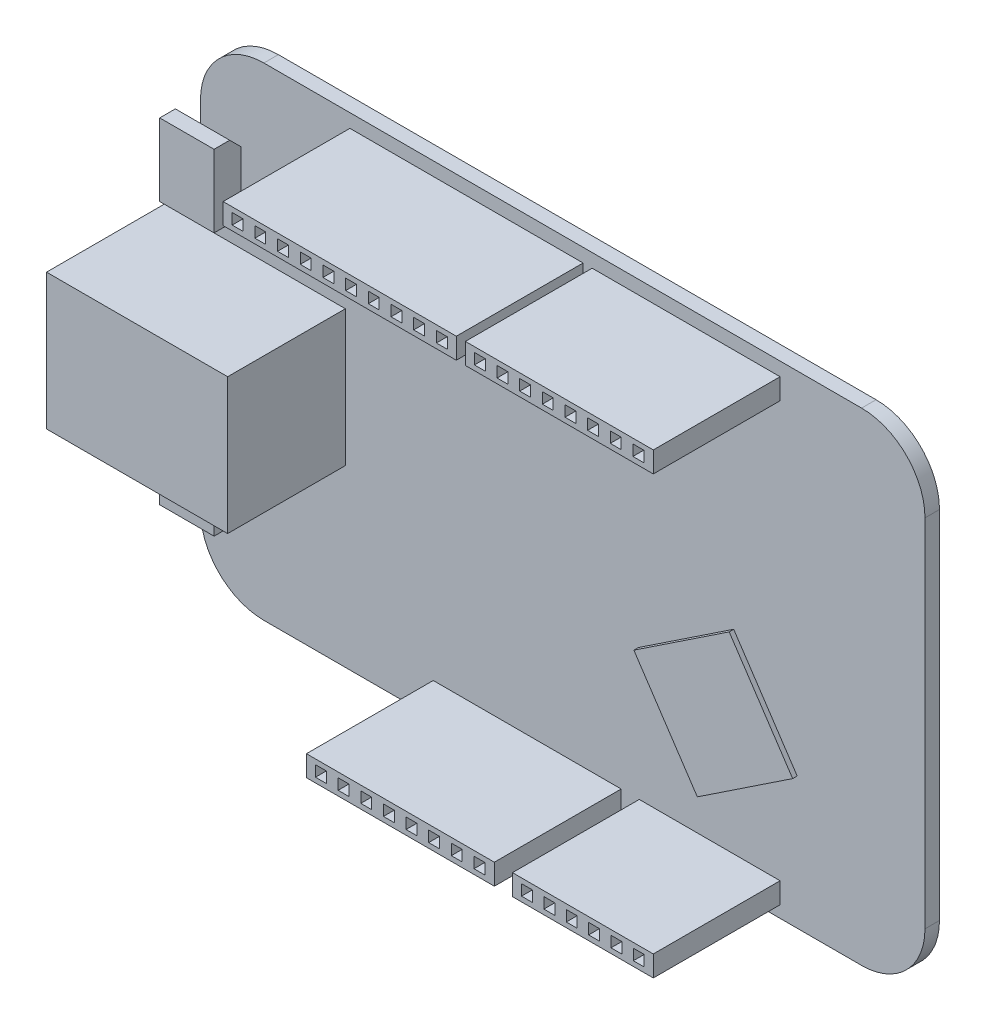
from build123d import *

# Parameters (mm, degrees)
ESQUISSE1_W         = 80
ESQUISSE1_H         = 53.3
BOSS_EXTRU_1_DEPTH  = 1.6
ESQUISSE4_W         = 15.55
ESQUISSE4_H         = 2.3
ESQUISSE4_W_2       = 1.2
ESQUISSE4_H_2       = 1.2
BOSS_EXTRU_4_DEPTH  = 14
ESQUISSE8_W         = 20.75
ESQUISSE8_H         = 2.3
ESQUISSE8_W_2       = 1.2
ESQUISSE8_H_2       = 1.2
BOSS_EXTRU_6_DEPTH  = 14
ESQUISSE19_W        = 20.75
ESQUISSE19_H        = 2.3
ESQUISSE19_W_2      = 1.2
ESQUISSE19_H_2      = 1.2
BOSS_EXTRU_15_DEPTH = 14
ESQUISSE20_W        = 25.75
ESQUISSE20_H        = 2.3
ESQUISSE20_W_2      = 1.2
ESQUISSE20_H_2      = 1.2
BOSS_EXTRU_16_DEPTH = 14
FILLET1_R           = 7
BOSS_EXTRUDE1_DEPTH = 0.5
SKETCH2_W           = 20
SKETCH2_H           = 15
BOSS_EXTRUDE2_DEPTH = 13
SKETCH3_W           = 6
SKETCH3_H           = 8
BOSS_EXTRUDE3_DEPTH = 3
CUT_EXTRUDE1_DEPTH  = 6
CUT_EXTRUDE2_DEPTH  = 18


with BuildPart() as part:
    # Esquisse1 → Boss.-Extru.1 (new body)
    with BuildSketch(Plane.XY):
        with Locations((40, 26.65)):
            Rectangle(ESQUISSE1_W, ESQUISSE1_H)
    extrude(amount=BOSS_EXTRU_1_DEPTH)

    # Fillet1
    fillet1_edges = [part.edges().sort_by_distance(p)[0] for p in [
        (0, 0, 0.8),
        (0, 53.3, 0.8),
        (80, 53.3, 0.8),
        (80, 0, 0.8),
    ]]
    fillet(fillet1_edges, radius=FILLET1_R)

    # Sketch1 → Boss-Extrude1 (add)
    with BuildSketch(Plane.XY.offset(1.6)):
        Polygon((55.362625471, 7.551462799), (65.888368636, 14.561039023), (58.878792412, 25.086782188), (48.353049247, 18.077205964), align=None)
    extrude(amount=BOSS_EXTRUDE1_DEPTH)

    # Sketch2 → Boss-Extrude2 (add)
    with BuildSketch(Plane.XY.offset(1.6)):
        with Locations((6, 26.8)):
            Rectangle(SKETCH2_W, SKETCH2_H)
    extrude(amount=BOSS_EXTRUDE2_DEPTH)

    # Sketch3 → Boss-Extrude3 (add)
    with BuildSketch(Plane.XY.offset(1.6)):
        with Locations((1.5, 41.3)):
            Rectangle(SKETCH3_W, SKETCH3_H)
        with Locations((1.5, 12.3)):
            Rectangle(SKETCH3_W, SKETCH3_H)
    extrude(amount=BOSS_EXTRUDE3_DEPTH)

    # Sketch4 → Cut-Extrude1 (cut)
    with BuildSketch(Plane.ZY.offset(1.5)):
        Polygon((2.872954099, 8.3), (1.6, 9.572630293), (1.6, 8.3), align=None)
        Polygon((2.872954099, 16.3), (1.6, 16.3), (1.6, 15.027369707), align=None)
        Polygon((2.873277986, 37.3), (1.6, 38.572954099), (1.6, 37.3), align=None)
        Polygon((2.872630293, 45.3), (1.6, 44.027045901), (1.6, 45.3), align=None)
    extrude(amount=-CUT_EXTRUDE1_DEPTH, mode=Mode.SUBTRACT)

    # Sketch5 → Cut-Extrude2 (cut)
    with BuildSketch(Plane.ZY.offset(4)):
        Polygon((13.6, 33.3), (3.6, 33.3), (3.6, 30.3), (2.6, 30.3), (2.6, 23.3), (3.6, 23.3), (3.6, 20.3), (13.6, 20.3), align=None)
    extrude(amount=-CUT_EXTRUDE2_DEPTH, mode=Mode.SUBTRACT)


with BuildPart() as body_2:
    # Esquisse4 → Boss.-Extru.4 (new body)
    with BuildSketch(Plane.XY.offset(1.6)):
        with Locations((56.225, 2.45)):
            Rectangle(ESQUISSE4_W, ESQUISSE4_H)
        with Locations((50.05, 2.45)):
            Rectangle(ESQUISSE4_W_2, ESQUISSE4_H_2, mode=Mode.SUBTRACT)
        with Locations((52.52, 2.45)):
            Rectangle(ESQUISSE4_W_2, ESQUISSE4_H_2, mode=Mode.SUBTRACT)
        with Locations((54.99, 2.45)):
            Rectangle(ESQUISSE4_W_2, ESQUISSE4_H_2, mode=Mode.SUBTRACT)
        with Locations((57.46, 2.45)):
            Rectangle(ESQUISSE4_W_2, ESQUISSE4_H_2, mode=Mode.SUBTRACT)
        with Locations((59.93, 2.45)):
            Rectangle(ESQUISSE4_W_2, ESQUISSE4_H_2, mode=Mode.SUBTRACT)
        with Locations((62.4, 2.45)):
            Rectangle(ESQUISSE4_W_2, ESQUISSE4_H_2, mode=Mode.SUBTRACT)
    extrude(amount=BOSS_EXTRU_4_DEPTH)


with BuildPart() as body_3:
    # Esquisse8 → Boss.-Extru.6 (new body)
    with BuildSketch(Plane.XY.offset(1.6)):
        with Locations((36.075, 2.45)):
            Rectangle(ESQUISSE8_W, ESQUISSE8_H)
        with Locations((27.3, 2.45)):
            Rectangle(ESQUISSE8_W_2, ESQUISSE8_H_2, mode=Mode.SUBTRACT)
        with Locations((29.8, 2.45)):
            Rectangle(ESQUISSE8_W_2, ESQUISSE8_H_2, mode=Mode.SUBTRACT)
        with Locations((32.3, 2.45)):
            Rectangle(ESQUISSE8_W_2, ESQUISSE8_H_2, mode=Mode.SUBTRACT)
        with Locations((34.8, 2.45)):
            Rectangle(ESQUISSE8_W_2, ESQUISSE8_H_2, mode=Mode.SUBTRACT)
        with Locations((37.3, 2.45)):
            Rectangle(ESQUISSE8_W_2, ESQUISSE8_H_2, mode=Mode.SUBTRACT)
        with Locations((39.8, 2.45)):
            Rectangle(ESQUISSE8_W_2, ESQUISSE8_H_2, mode=Mode.SUBTRACT)
        with Locations((42.3, 2.45)):
            Rectangle(ESQUISSE8_W_2, ESQUISSE8_H_2, mode=Mode.SUBTRACT)
        with Locations((44.8, 2.45)):
            Rectangle(ESQUISSE8_W_2, ESQUISSE8_H_2, mode=Mode.SUBTRACT)
    extrude(amount=BOSS_EXTRU_6_DEPTH)


with BuildPart() as body_4:
    # Esquisse19 → Boss.-Extru.15 (new body)
    with BuildSketch(Plane.XY.offset(1.6)):
        with Locations((53.625, 50.65)):
            Rectangle(ESQUISSE19_W, ESQUISSE19_H)
        with Locations((44.85, 50.65)):
            Rectangle(ESQUISSE19_W_2, ESQUISSE19_H_2, mode=Mode.SUBTRACT)
        with Locations((47.35, 50.65)):
            Rectangle(ESQUISSE19_W_2, ESQUISSE19_H_2, mode=Mode.SUBTRACT)
        with Locations((49.85, 50.65)):
            Rectangle(ESQUISSE19_W_2, ESQUISSE19_H_2, mode=Mode.SUBTRACT)
        with Locations((52.35, 50.65)):
            Rectangle(ESQUISSE19_W_2, ESQUISSE19_H_2, mode=Mode.SUBTRACT)
        with Locations((54.85, 50.65)):
            Rectangle(ESQUISSE19_W_2, ESQUISSE19_H_2, mode=Mode.SUBTRACT)
        with Locations((57.35, 50.65)):
            Rectangle(ESQUISSE19_W_2, ESQUISSE19_H_2, mode=Mode.SUBTRACT)
        with Locations((59.85, 50.65)):
            Rectangle(ESQUISSE19_W_2, ESQUISSE19_H_2, mode=Mode.SUBTRACT)
        with Locations((62.35, 50.65)):
            Rectangle(ESQUISSE19_W_2, ESQUISSE19_H_2, mode=Mode.SUBTRACT)
    extrude(amount=BOSS_EXTRU_15_DEPTH)


with BuildPart() as body_5:
    # Esquisse20 → Boss.-Extru.16 (new body)
    with BuildSketch(Plane.XY.offset(1.6)):
        with Locations((29.375, 50.65)):
            Rectangle(ESQUISSE20_W, ESQUISSE20_H)
        with Locations((40.65, 50.65)):
            Rectangle(ESQUISSE20_W_2, ESQUISSE20_H_2, mode=Mode.SUBTRACT)
        with Locations((38.144444444, 50.65)):
            Rectangle(ESQUISSE20_W_2, ESQUISSE20_H_2, mode=Mode.SUBTRACT)
        with Locations((35.638888889, 50.65)):
            Rectangle(ESQUISSE20_W_2, ESQUISSE20_H_2, mode=Mode.SUBTRACT)
        with Locations((33.133333333, 50.65)):
            Rectangle(ESQUISSE20_W_2, ESQUISSE20_H_2, mode=Mode.SUBTRACT)
        with Locations((30.627777778, 50.65)):
            Rectangle(ESQUISSE20_W_2, ESQUISSE20_H_2, mode=Mode.SUBTRACT)
        with Locations((28.122222222, 50.65)):
            Rectangle(ESQUISSE20_W_2, ESQUISSE20_H_2, mode=Mode.SUBTRACT)
        with Locations((25.616666667, 50.65)):
            Rectangle(ESQUISSE20_W_2, ESQUISSE20_H_2, mode=Mode.SUBTRACT)
        with Locations((23.111111111, 50.65)):
            Rectangle(ESQUISSE20_W_2, ESQUISSE20_H_2, mode=Mode.SUBTRACT)
        with Locations((20.605555556, 50.65)):
            Rectangle(ESQUISSE20_W_2, ESQUISSE20_H_2, mode=Mode.SUBTRACT)
        with Locations((18.1, 50.65)):
            Rectangle(ESQUISSE20_W_2, ESQUISSE20_H_2, mode=Mode.SUBTRACT)
    extrude(amount=BOSS_EXTRU_16_DEPTH)


solid = Compound([part.part, body_2.part, body_3.part, body_4.part, body_5.part])
